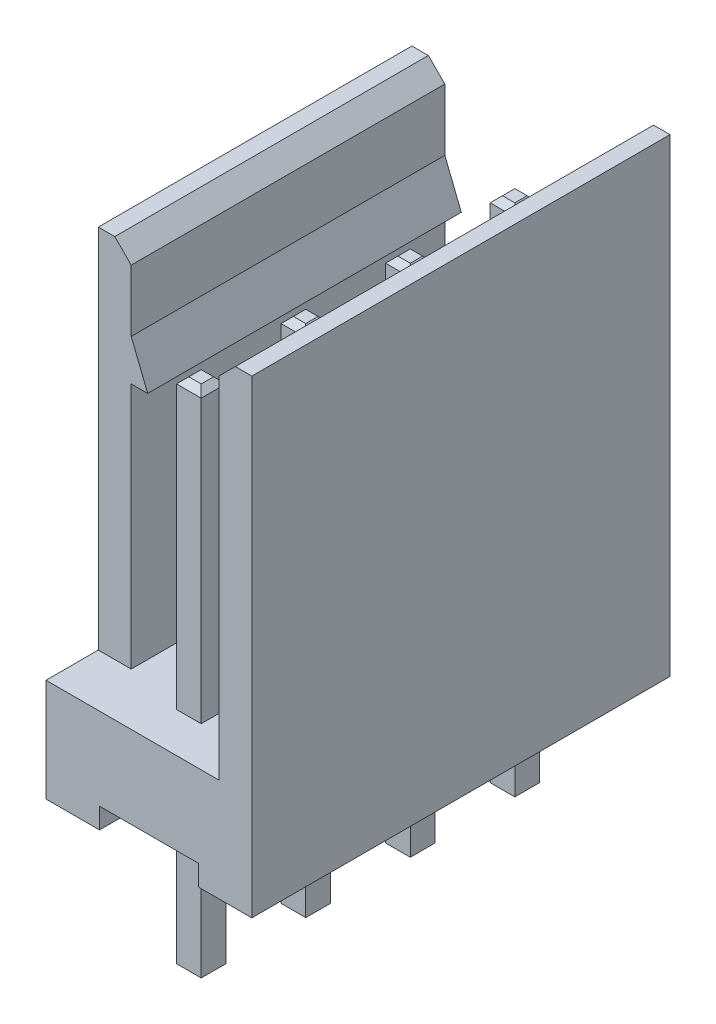
from build123d import *

# Parameters (mm, degrees)
BOSS_EXTRU_1_DEPTH      = 10.16
ESQUISSE3_W             = 0.8
ESQUISSE3_H             = 1.27
ENL_V_MAT_EXTRU_1_DEPTH = 8.9
ESQUISSE4_W             = 2.4
ESQUISSE4_H             = 0.5
ENL_V_MAT_EXTRU_2_DEPTH = 11.16
ESQUISSE2_W             = 0.6
ESQUISSE2_H             = 0.6
BOSS_EXTRU_2_DEPTH      = 3.5
BOSS_EXTRU_2_DEPTH_BACK = 9
BOSS_EXTRU_3_DEPTH      = 7.62
CHANFREIN4_SIZE         = 0.15
CHANFREIN5_SIZE         = 0.4


with BuildPart() as part:
    # Esquisse1 → Boss.-Extru.1 (new body)
    with BuildSketch(Plane.XY):
        Polygon((0, 11.4), (0, 0), (5, 0), (5, 11.4), (4.2, 11.4), (4.2, 2.5), (0.8, 2.5), (0.8, 11.4), align=None)
    extrude(amount=BOSS_EXTRU_1_DEPTH)

    # Esquisse3 → Enlèv. mat.-Extru.1 (cut)
    with BuildSketch(Plane(origin=(0, 11.4, 0), x_dir=(1, 0, 0), z_dir=(0, 1, 0))):
        with Locations((0.4, -0.635)):
            Rectangle(ESQUISSE3_W, ESQUISSE3_H)
        with Locations((0.4, -9.525)):
            Rectangle(ESQUISSE3_W, ESQUISSE3_H)
    extrude(amount=-ENL_V_MAT_EXTRU_1_DEPTH, mode=Mode.SUBTRACT)

    # Esquisse4 → Enlèv. mat.-Extru.2 (cut, through all)
    with BuildSketch(Plane.XY.offset(10.16)):
        with Locations((2.5, 0.25)):
            Rectangle(ESQUISSE4_W, ESQUISSE4_H)
    extrude(amount=-ENL_V_MAT_EXTRU_2_DEPTH, mode=Mode.SUBTRACT)

    # Esquisse2 → Boss.-Extru.2 (add, two sides)
    with BuildSketch(Plane.XZ.offset(-0.5)) as boss_extru_2_sk:
        with Locations((2.5, 8.89)):
            Rectangle(ESQUISSE2_W, ESQUISSE2_H)
        with Locations((2.5, 1.27)):
            Rectangle(ESQUISSE2_W, ESQUISSE2_H)
        with Locations((2.5, 6.35)):
            Rectangle(ESQUISSE2_W, ESQUISSE2_H)
        with Locations((2.5, 3.81)):
            Rectangle(ESQUISSE2_W, ESQUISSE2_H)
    extrude(amount=BOSS_EXTRU_2_DEPTH)
    extrude(boss_extru_2_sk.sketch, amount=-BOSS_EXTRU_2_DEPTH_BACK)

    # Esquisse5 → Boss.-Extru.3 (add)
    with BuildSketch(Plane.XY.offset(8.89)):
        Polygon((0.8, 9.5), (1.2, 8.5), (0.8, 8.5), align=None)
    extrude(amount=-BOSS_EXTRU_3_DEPTH)

    # Chanfrein4
    chanfrein4_edges = [part.edges().sort_by_distance(p)[0] for p in [
        (2.8, 9.5, 6.35),
        (2.5, 9.5, 6.05),
        (2.2, 9.5, 6.35),
        (2.5, 9.5, 6.65),
        (2.8, -3, 6.35),
        (2.5, -3, 6.65),
        (2.2, -3, 6.35),
        (2.5, -3, 6.05),
        (2.8, 9.5, 3.81),
        (2.5, 9.5, 3.51),
        (2.2, 9.5, 3.81),
        (2.5, 9.5, 4.11),
        (2.8, -3, 3.81),
        (2.5, -3, 4.11),
        (2.2, -3, 3.81),
        (2.5, -3, 3.51),
        (2.8, 9.5, 8.89),
        (2.5, 9.5, 8.59),
        (2.2, 9.5, 8.89),
        (2.5, 9.5, 9.19),
        (2.8, -3, 8.89),
        (2.5, -3, 9.19),
        (2.2, -3, 8.89),
        (2.5, -3, 8.59),
        (2.8, 9.5, 1.27),
        (2.5, 9.5, 0.97),
        (2.2, 9.5, 1.27),
        (2.5, 9.5, 1.57),
        (2.8, -3, 1.27),
        (2.5, -3, 1.57),
        (2.2, -3, 1.27),
        (2.5, -3, 0.97),
    ]]
    chamfer(chanfrein4_edges, length=CHANFREIN4_SIZE)

    # Chanfrein5
    chanfrein5_edges = [part.edges().sort_by_distance(p)[0] for p in [
        (4.2, 11.4, 5.08),
        (0.8, 11.4, 5.08),
    ]]
    chamfer(chanfrein5_edges, length=CHANFREIN5_SIZE)


solid = part.part
